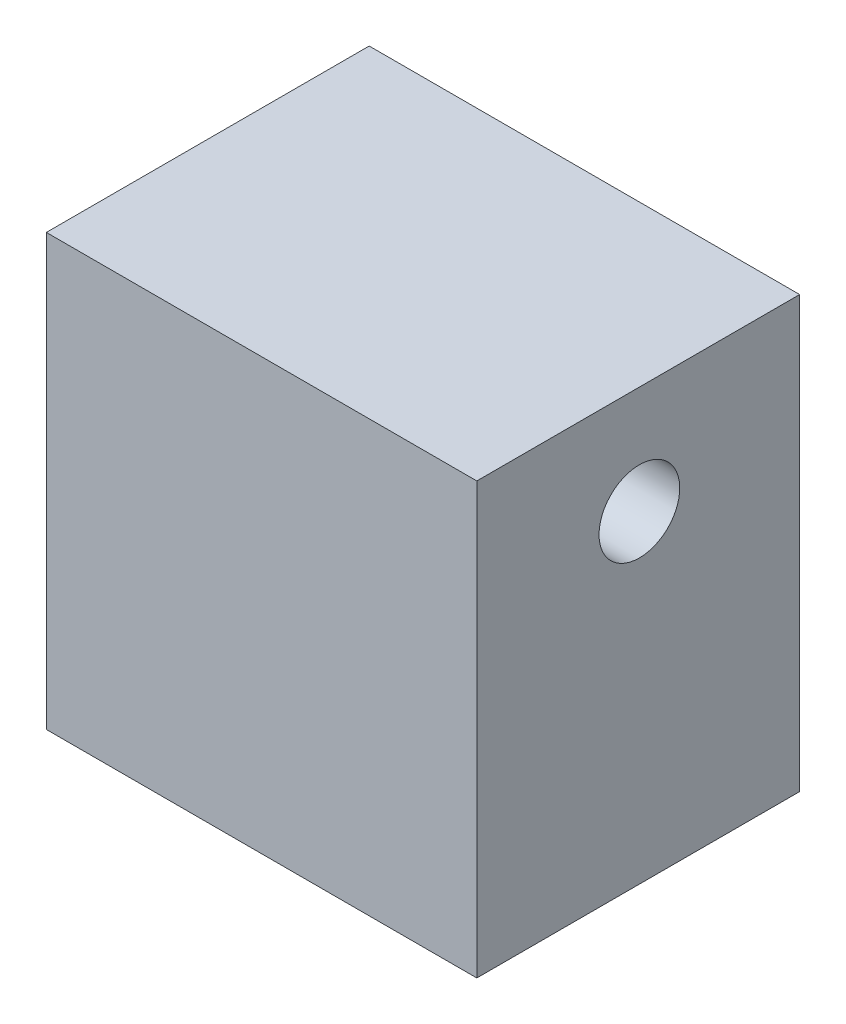
from build123d import *

# Parameters (mm, degrees)
SKETCH1_W           = 50.8
SKETCH1_H           = 50.8
BOSS_EXTRUDE1_DEPTH = 38.1
SKETCH3_R           = 5.588
CUT_EXTRUDE1_DEPTH  = 25.4
SKETCH4_R           = 4.7625
CUT_EXTRUDE2_DEPTH  = 51.8


with BuildPart() as part:
    # Sketch1 → Boss-Extrude1 (new body)
    with BuildSketch(Plane.XY):
        Rectangle(SKETCH1_W, SKETCH1_H)
    extrude(amount=BOSS_EXTRUDE1_DEPTH)

    # Sketch3 → Cut-Extrude1 (cut)
    with BuildSketch(Plane.XZ.offset(25.4)):
        with Locations((0, 19.05)):
            Circle(SKETCH3_R)
    extrude(amount=-CUT_EXTRUDE1_DEPTH, mode=Mode.SUBTRACT)

    # Sketch4 → Cut-Extrude2 (cut, through all)
    with BuildSketch(Plane.ZY.offset(25.4)):
        with Locations((18.915028582, 12.7)):
            Circle(SKETCH4_R)
    extrude(amount=-CUT_EXTRUDE2_DEPTH, mode=Mode.SUBTRACT)


solid = part.part
